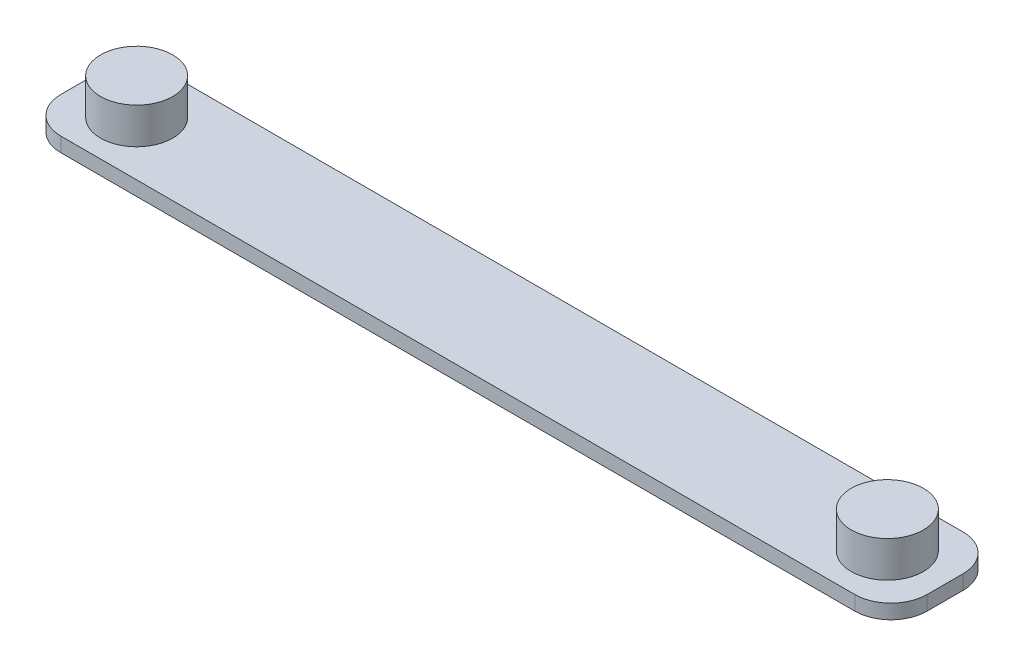
from build123d import *

# Parameters (mm, degrees)
BOSS_EXTRUDE2_DEPTH = 2
SKETCH3_R           = 5
BOSS_EXTRUDE3_DEPTH = 5


with BuildPart() as part:
    # Sketch1 → Boss-Extrude2 (new body)
    with BuildSketch(Plane(origin=(0, 0, 0), x_dir=(1, 0, 0), z_dir=(0, 1, 0))):
        with BuildLine():
            Line((-55, -7.5), (55, -7.5))
            ThreePointArc((55, -7.5), (58.535533906, -6.035533906), (60, -2.5))
            Line((60, -2.5), (60, 2.5))
            ThreePointArc((60, 2.5), (58.535533906, 6.035533906), (55, 7.5))
            Line((55, 7.5), (-55, 7.5))
            ThreePointArc((-55, 7.5), (-58.535533906, 6.035533906), (-60, 2.5))
            Line((-60, 2.5), (-60, -2.5))
            ThreePointArc((-60, -2.5), (-58.535533906, -6.035533906), (-55, -7.5))
        make_face()
    extrude(amount=BOSS_EXTRUDE2_DEPTH)

    # Sketch3 → Boss-Extrude3 (add)
    with BuildSketch(Plane(origin=(0, 2, 0), x_dir=(1, 0, 0), z_dir=(0, 1, 0))):
        with Locations((52, 0)):
            Circle(SKETCH3_R)
        with Locations((-52, 0)):
            Circle(SKETCH3_R)
    extrude(amount=BOSS_EXTRUDE3_DEPTH)


solid = part.part
